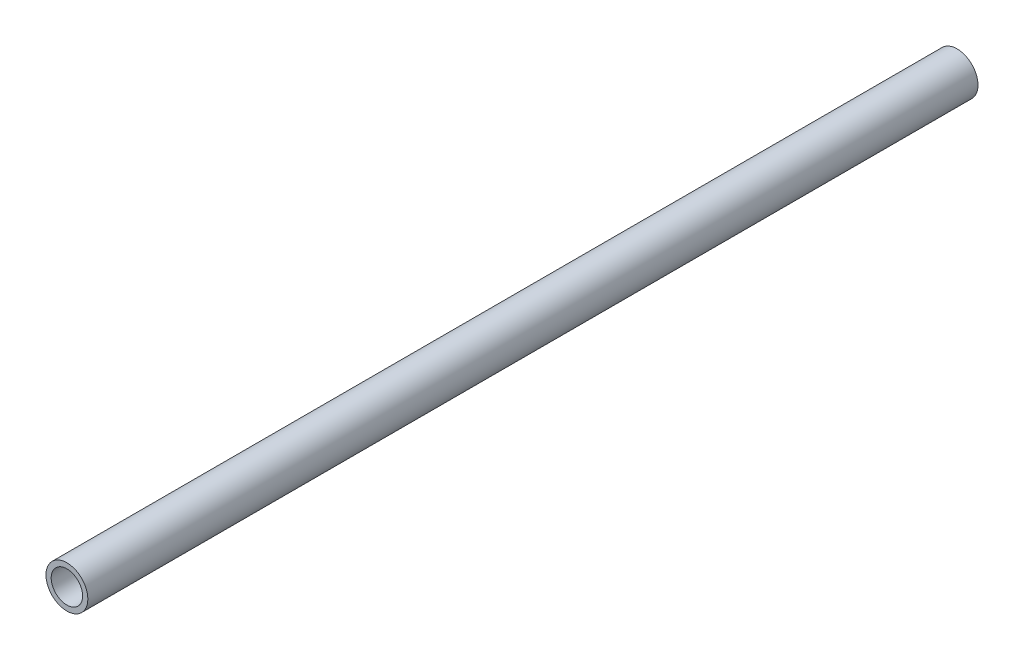
from build123d import *

# Parameters (mm, degrees)
SKETCH3_R                = 12.7
SKETCH3_R_2              = 9.525
BOSS_EXTRUDE1_DEPTH      = 457.2
BOSS_EXTRUDE1_DEPTH_BACK = 457.2
SKETCH5_R                = 12.7
CUT_EXTRUDE1_DEPTH       = 374.399999992


with BuildPart() as part:
    # Sketch3 → Boss-Extrude1 (new body, two sides)
    with BuildSketch(Plane.XY) as boss_extrude1_sk:
        Circle(SKETCH3_R)
        Circle(SKETCH3_R_2, mode=Mode.SUBTRACT)
    extrude(amount=BOSS_EXTRUDE1_DEPTH)
    extrude(boss_extrude1_sk.sketch, amount=-BOSS_EXTRUDE1_DEPTH_BACK)

    # Sketch5 → Cut-Extrude1 (cut)
    with BuildSketch(Plane.XY.offset(457.2)):
        Circle(SKETCH5_R)
    extrude(amount=-CUT_EXTRUDE1_DEPTH, mode=Mode.SUBTRACT)


solid = part.part
